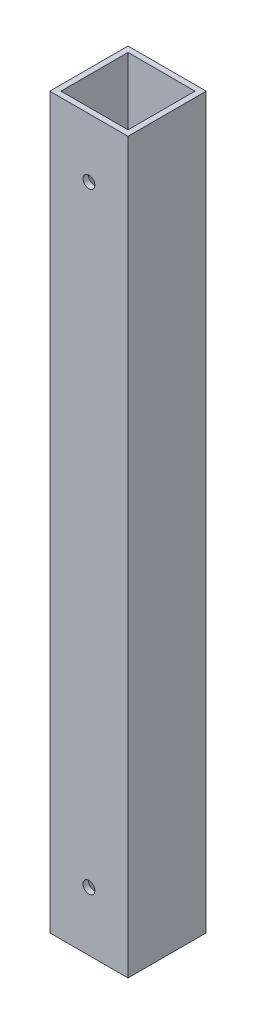
from build123d import *

# Parameters (mm, degrees)
BOSS_EXTRUDE1_DEPTH              = 207.16875
BOSS_EXTRUDE1_DEPTH_BACK         = 207.16875
SKETCH1_W                        = 44.45
SKETCH1_H                        = 44.45
SKETCH1_W_2                      = 38.1
SKETCH1_H_2                      = 38.1
F_17_64_0_26563_DIAMETER_HOLE1_D = 6.747002


with BuildPart() as part:
    # Sketch1 → Boss-Extrude1 (new, two sides: drawn at the far end of the back side and taken through both)
    with BuildSketch(Plane(origin=(0, 0, 0), x_dir=(1, 0, 0), z_dir=(0, 1, 0)).offset(-BOSS_EXTRUDE1_DEPTH_BACK)):
        Rectangle(SKETCH1_W, SKETCH1_H)
        Rectangle(SKETCH1_W_2, SKETCH1_H_2, mode=Mode.SUBTRACT)
    extrude(amount=BOSS_EXTRUDE1_DEPTH + BOSS_EXTRUDE1_DEPTH_BACK)

    # 17_64 _0.26563_ Diameter Hole1 (through all)
    with Locations(Plane.XY.offset(22.225)):
        with Locations((0, 173.609), (0, -173.609)):
            Hole(F_17_64_0_26563_DIAMETER_HOLE1_D / 2)


solid = part.part
